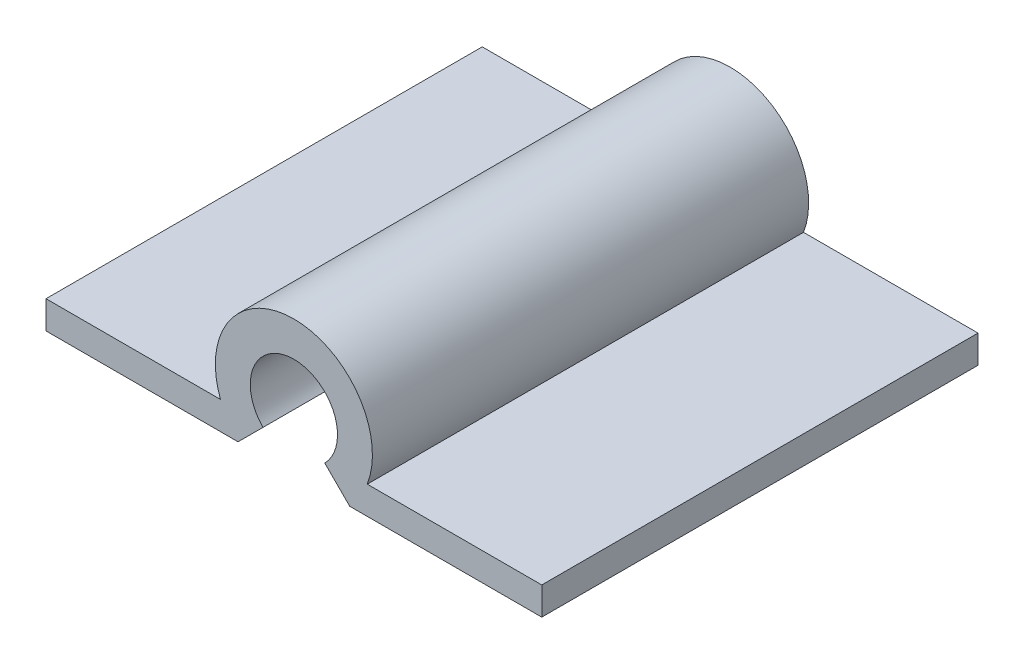
from build123d import *

# Parameters (mm, degrees)
BOSS_EXTRUDE1_DEPTH = 15.875


with BuildPart() as part:
    # Sketch1 → Boss-Extrude1 (new body)
    with BuildSketch(Plane.XY):
        with BuildLine():
            Line((-2.670777087, -1.016), (-9.020777087, -1.016))
            Line((-9.020777087, -1.016), (-9.020777087, -2.032))
            Line((-9.020777087, -2.032), (-2.032, -2.032))
            Line((-2.032, -2.032), (-1.122532015, -1.122532015))
            ThreePointArc((-1.122532015, -1.122532015), (0, 1.5875), (1.122532015, -1.122532015))
            Line((1.122532015, -1.122532015), (2.032, -2.032))
            Line((2.032, -2.032), (9.020777087, -2.032))
            Line((9.020777087, -2.032), (9.020777087, -1.016))
            Line((9.020777087, -1.016), (2.670777087, -1.016))
            ThreePointArc((2.670777087, -1.016), (0, 2.8575), (-2.670777087, -1.016))
        make_face()
    extrude(amount=BOSS_EXTRUDE1_DEPTH)


solid = part.part
